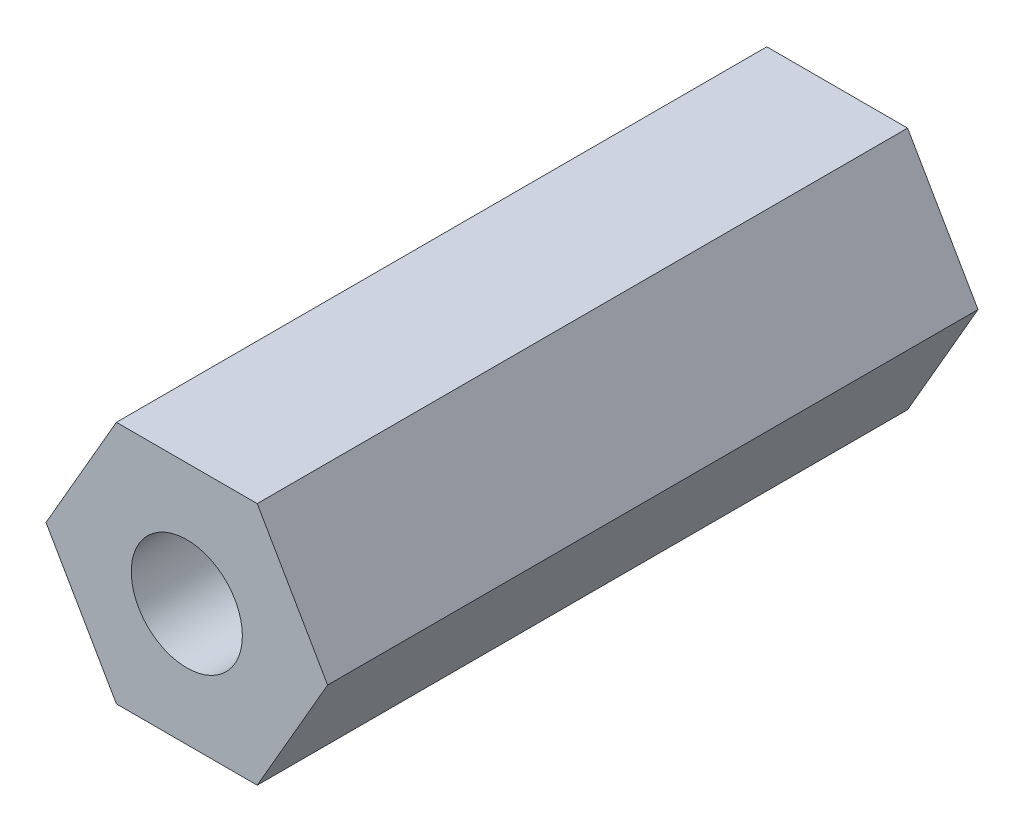
from build123d import *

# Parameters (mm, degrees)
EXTRUDE_1_DEPTH          = 12
HOLE_WIZARD_M2_5_1_D     = 2.05
HOLE_WIZARD_M2_5_1_DEPTH = 21.35
HOLE_WIZARD_M2_5_1_TIP   = 0.615882135


with BuildPart() as part:
    # 草图1 → 凸台-拉伸1 (new body)
    with BuildSketch(Plane.XY):
        Polygon((-1.299038106, 2.25), (-2.598076211, 0), (-1.299038106, -2.25), (1.299038106, -2.25), (2.598076211, 0), (1.299038106, 2.25), align=None)
    extrude(amount=EXTRUDE_1_DEPTH)

    # M2.5 螺纹孔1
    with Locations(Plane.XY.offset(12)):
        with Locations((0, 0)):
            Hole(HOLE_WIZARD_M2_5_1_D / 2, depth=HOLE_WIZARD_M2_5_1_DEPTH)
            with Locations((0, 0, -(HOLE_WIZARD_M2_5_1_DEPTH + HOLE_WIZARD_M2_5_1_TIP / 2))):  # 118° drill point
                Cone(0, HOLE_WIZARD_M2_5_1_D / 2, HOLE_WIZARD_M2_5_1_TIP, mode=Mode.SUBTRACT)


solid = part.part
